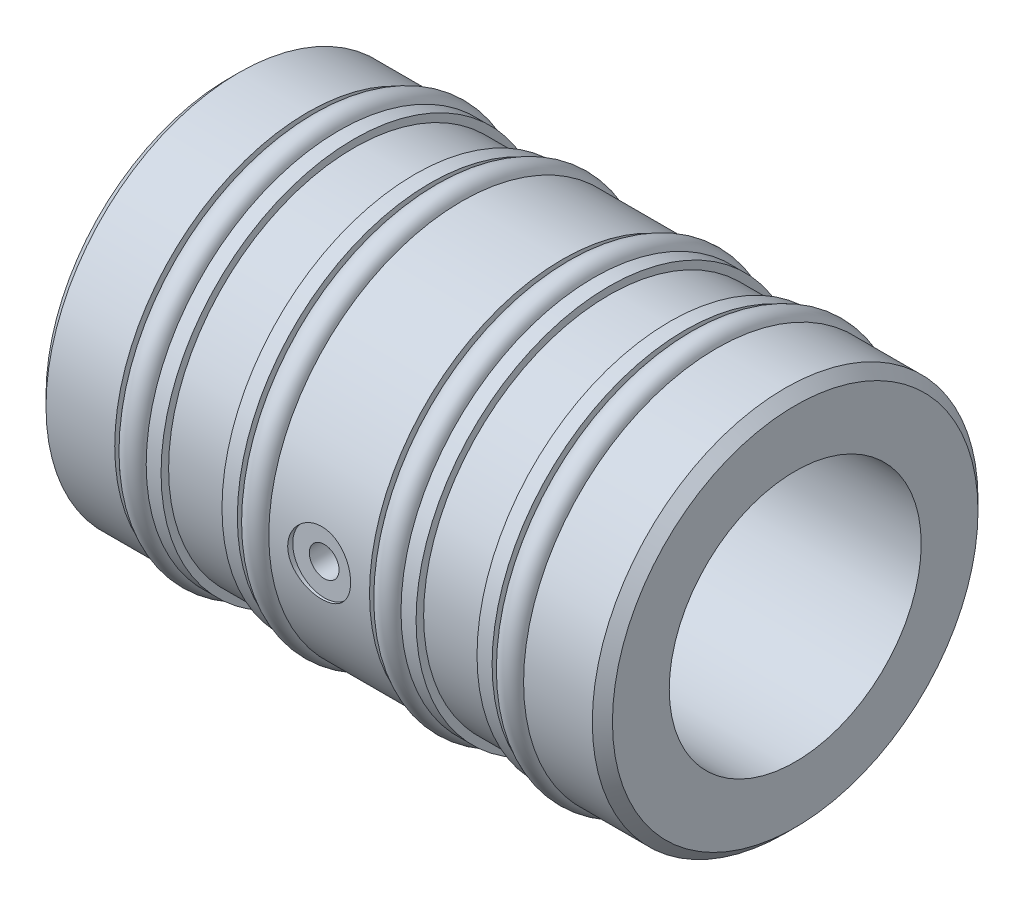
from build123d import *

# Parameters (mm, degrees)
CHAMFER1_SIZE                   = 1.016
F_1_4_0_25_DIAMETER_HOLE1_D     = 6.35
F_1_4_0_25_DIAMETER_HOLE1_DEPTH = 0.508
AIR_HOLE_D                      = 2.4892
AIR_HOLE_DEPTH                  = 6.35
AIR_HOLE_CBORE_D                = 2.9972
AIR_HOLE_CBORE_DEPTH            = 5.9944
AIR_HOLE_TIP                    = 0.747831126
SKETCH5_R                       = 1.30175


with BuildPart() as part:
    # Sketch1 → Revolve1 (revolve)
    with BuildSketch(Plane.XY, mode=Mode.PRIVATE) as revolve1_sk:
        Polygon((0, 12.71016), (57.15, 12.71016), (57.15, 19.4564), (49.1998, 19.4564), (49.1998, 17.4752), (46.0248, 17.4752), (46.0248, 19.4564), (44.5008, 19.4564), (44.5008, 18.6944), (38.354, 18.6944), (38.354, 19.4564), (36.83, 19.4564), (36.83, 17.4752), (33.655, 17.4752), (33.655, 19.4564), (23.495, 19.4564), (23.495, 17.4752), (20.32, 17.4752), (20.32, 19.4564), (18.7706, 19.4564), (18.7706, 18.6944), (12.6238, 18.6944), (12.6238, 19.4564), (11.1252, 19.4564), (11.1252, 17.4752), (7.9502, 17.4752), (7.9502, 19.4564), (0, 19.4564), align=None)
    revolve(revolve1_sk.sketch.rotate(Axis((0, 0, 0), (1, 0, 0)), 90), axis=Axis((0, 0, 0), (1, 0, 0)))  # turned: the seam where the file's is

    # Chamfer1
    chamfer1_edges = [part.edges().sort_by_distance(p)[0] for p in [
        (57.15, 0, -19.4564),
        (0, 0, -19.4564),
    ]]
    chamfer(chamfer1_edges, length=CHAMFER1_SIZE)

    # 1/4 (0.25) Diameter Hole1
    with Locations(Plane(origin=(28.575, 0, 19.4564), x_dir=(1, 0, 0), z_dir=(0, 0, 1))):
        with Locations((0, 0)):
            Hole(F_1_4_0_25_DIAMETER_HOLE1_D / 2, depth=F_1_4_0_25_DIAMETER_HOLE1_DEPTH)

    # Air Hole
    with Locations(Plane.XY.offset(18.9484)):
        with Locations((28.575, 0)):
            CounterBoreHole(AIR_HOLE_D / 2, AIR_HOLE_CBORE_D / 2, AIR_HOLE_CBORE_DEPTH, depth=AIR_HOLE_DEPTH)
            with Locations((0, 0, -(AIR_HOLE_DEPTH + AIR_HOLE_TIP / 2))):  # 118° drill point
                Cone(0, AIR_HOLE_D / 2, AIR_HOLE_TIP, mode=Mode.SUBTRACT)

    # Sketch5 → Revolve2 (revolve)
    with BuildSketch(Plane.XY, mode=Mode.PRIVATE) as revolve2_sk:
        with Locations((9.5377, 18.77441)):
            Circle(SKETCH5_R)
        with Locations((21.9075, 18.77441)):
            Circle(SKETCH5_R)
        with Locations((35.2425, 18.77441)):
            Circle(SKETCH5_R)
        with Locations((47.6123, 18.77441)):
            Circle(SKETCH5_R)
    revolve(revolve2_sk.sketch.rotate(Axis((0, 0, 0), (1, 0, 0)), 90), axis=Axis((0, 0, 0), (1, 0, 0)))  # turned: the seam where the file's is


solid = part.part
